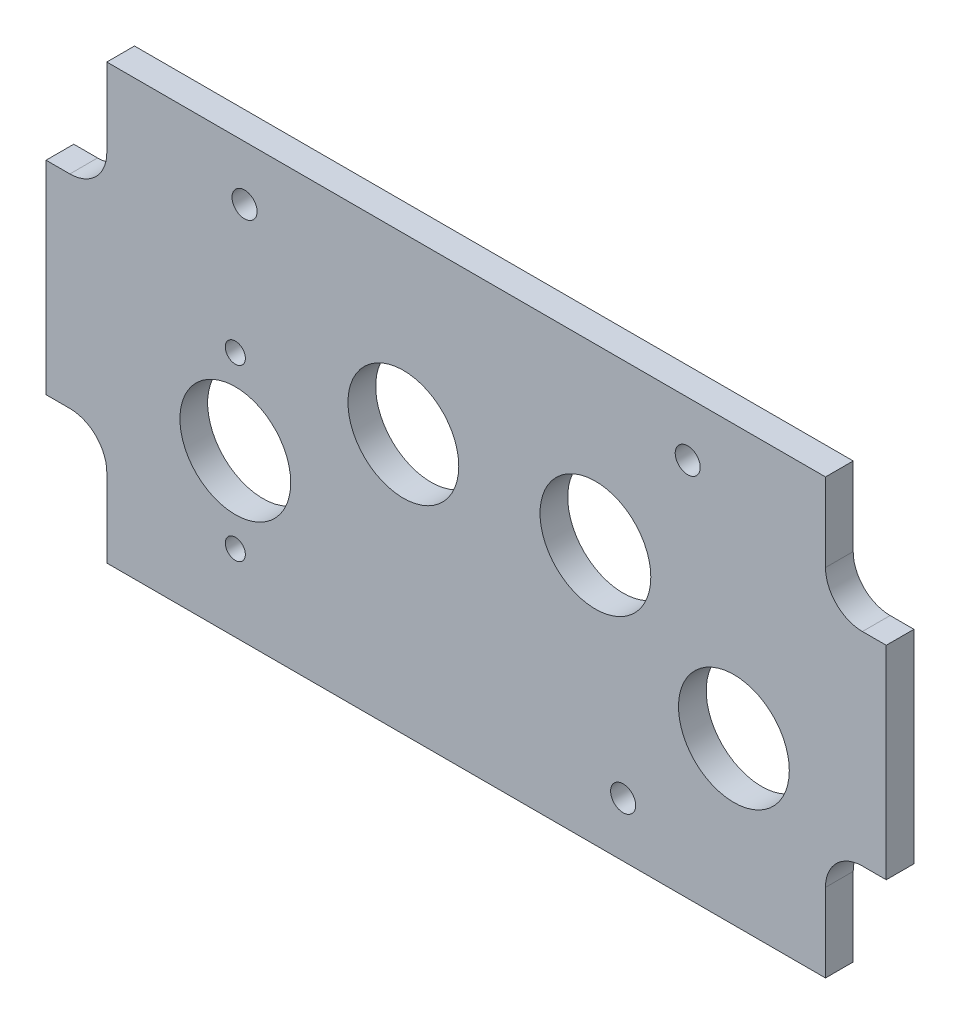
from build123d import *

# Parameters (mm, degrees)
BOSS_EXTRUDE1_DEPTH         = 4.7625
F_4_CLEARANCE_HOLE1_D       = 3.4544
F_6_CLEARANCE_HOLE1_D       = 4.3053
F_3_4_0_75_DIAMETER_HOLE1_D = 19.05


with BuildPart() as part:
    # Sketch1 → Boss-Extrude1 (new body)
    with BuildSketch(Plane.XY):
        with BuildLine():
            Line((11.2395, 14.2875), (11.2395, 0.79375))
            Line((11.2395, 0.79375), (134.8105, 0.79375))
            Line((134.8105, 0.79375), (134.8105, 14.2875))
            ThreePointArc((134.8105, 14.2875), (136.670371939, 18.777628061), (141.1605, 20.6375))
            Line((141.1605, 20.6375), (145.25625, 20.6375))
            Line((145.25625, 20.6375), (145.25625, 55.5625))
            Line((145.25625, 55.5625), (141.1605, 55.5625))
            ThreePointArc((141.1605, 55.5625), (136.670371939, 57.422371939), (134.8105, 61.9125))
            Line((134.8105, 61.9125), (134.8105, 75.40625))
            Line((134.8105, 75.40625), (11.2395, 75.40625))
            Line((11.2395, 75.40625), (11.2395, 61.9125))
            ThreePointArc((11.2395, 61.9125), (9.379628061, 57.422371939), (4.8895, 55.5625))
            Line((4.8895, 55.5625), (0.79375, 55.5625))
            Line((0.79375, 55.5625), (0.79375, 20.6375))
            Line((0.79375, 20.6375), (4.8895, 20.6375))
            ThreePointArc((4.8895, 20.6375), (9.379628061, 18.777628061), (11.2395, 14.2875))
        make_face()
    extrude(amount=BOSS_EXTRUDE1_DEPTH)

    # #4 Clearance Hole1 (through all)
    with Locations(Plane.XY.offset(4.7625)):
        with Locations((33.3375, 43.18), (33.3375, 13.97)):
            Hole(F_4_CLEARANCE_HOLE1_D / 2)

    # #6 Clearance Hole1 (through all)
    with Locations(Plane.XY.offset(4.7625)):
        with Locations((34.925, 66.04), (111.125, 66.04), (100.01504, 10.16)):
            Hole(F_6_CLEARANCE_HOLE1_D / 2)

    # 3/4 (0.75) Diameter Hole1 (through all)
    with Locations(Plane.XY.offset(4.7625)):
        with Locations((119.0625, 28.575), (95.25, 45.466), (62.23, 45.466), (33.3375, 28.575)):
            Hole(F_3_4_0_75_DIAMETER_HOLE1_D / 2)


solid = part.part
